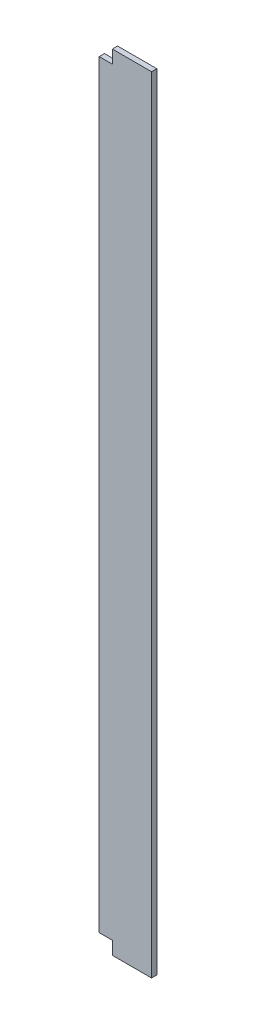
from build123d import *

# Parameters (mm, degrees)
ESBO_O1_W                = 200
ESBO_O1_H                = 20
RESSALTO_EXTRUS_O1_DEPTH = 3000
ESBO_O2_W                = 50
ESBO_O2_H                = 50
CORTE_EXTRUS_O1_DEPTH    = 21
ESBO_O3_W                = 50
ESBO_O3_H                = 50
CORTE_EXTRUS_O2_DEPTH    = 21


with BuildPart() as part:
    # Esboço1 → Ressalto-extrusão1 (new body)
    with BuildSketch(Plane(origin=(0, 0, 0), x_dir=(1, 0, 0), z_dir=(0, 1, 0))):
        with Locations((-1056.483688544, 794.687242443)):
            Rectangle(ESBO_O1_W, ESBO_O1_H)
    extrude(amount=RESSALTO_EXTRUS_O1_DEPTH)

    # Esboço2 → Corte-extrusão1 (cut, through all)
    with BuildSketch(Plane.XY.offset(-784.687242443)):
        with Locations((-1131.483688544, 25)):
            Rectangle(ESBO_O2_W, ESBO_O2_H)
    extrude(amount=-CORTE_EXTRUS_O1_DEPTH, mode=Mode.SUBTRACT)

    # Esboço3 → Corte-extrusão2 (cut, through all)
    with BuildSketch(Plane.XY.offset(-784.687242443)):
        with Locations((-1131.483688544, 2975)):
            Rectangle(ESBO_O3_W, ESBO_O3_H)
    extrude(amount=-CORTE_EXTRUS_O2_DEPTH, mode=Mode.SUBTRACT)


solid = part.part
